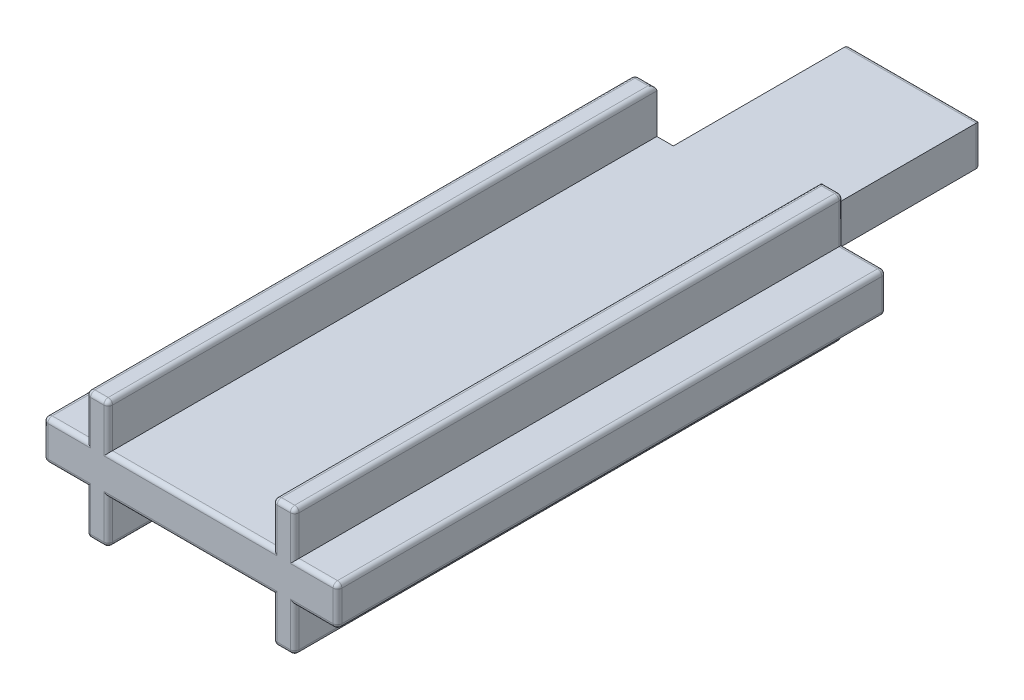
from build123d import *

# Parameters (mm, degrees)
AUFSATZ_LINEAR_AUSTRAGEN1_DEPTH = 25
SKIZZE2_W                       = 6
SKIZZE2_H                       = 1.8
AUFSATZ_LINEAR_AUSTRAGEN2_DEPTH = 8
VERRUNDUNG1_R                   = 0.2


with BuildPart() as part:
    # Skizze1 → Aufsatz-Linear austragen1 (new body)
    with BuildSketch(Plane.XY):
        Polygon((-4.75, 0.9), (-6.7, 0.9), (-6.7, -0.9), (-4.75, -0.9), (-4.75, -2.9), (-3.75, -2.9), (-3.75, -0.9), (3.75, -0.9), (3.75, -2.9), (4.75, -2.9), (4.75, -0.9), (6.7, -0.9), (6.7, 0.9), (4.75, 0.9), (4.75, 2.9), (3.75, 2.9), (3.75, 0.9), (-3.75, 0.9), (-3.75, 2.9), (-4.75, 2.9), align=None)
    extrude(amount=AUFSATZ_LINEAR_AUSTRAGEN1_DEPTH)

    # Skizze2 → Aufsatz-Linear austragen2 (add)
    with BuildSketch(Plane(origin=(0, 0, 0), x_dir=(-1, 0, 0), z_dir=(0, 0, -1))):
        Rectangle(SKIZZE2_W, SKIZZE2_H)
    extrude(amount=AUFSATZ_LINEAR_AUSTRAGEN2_DEPTH)

    # Verrundung1
    verrundung1_edges = [part.edges().sort_by_distance(p)[0] for p in [
        (-4.75, -1.9, 25),
        (-4.25, -2.9, 25),
        (-5.725, 0.9, 0),
        (-4.75, 1.9, 0),
        (-4.25, 2.9, 0),
        (-3.75, -1.9, 25),
        (4.25, 2.9, 0),
        (4.75, 1.9, 0),
        (5.725, 0.9, 0),
        (6.7, 0, 0),
        (5.725, -0.9, 0),
        (4.75, -1.9, 0),
        (4.25, -2.9, 0),
        (0, -0.9, 25),
        (-4.25, -2.9, 0),
        (-4.75, -1.9, 0),
        (-5.725, -0.9, 0),
        (-6.7, 0, 0),
        (3.75, -1.9, 25),
        (4.25, -2.9, 25),
        (-6.7, 0.9, 12.5),
        (-4.75, 2.9, 12.5),
        (-3.75, 2.9, 12.5),
        (3.75, 2.9, 12.5),
        (4.75, 2.9, 12.5),
        (6.7, 0.9, 12.5),
        (6.7, -0.9, 12.5),
        (4.75, -2.9, 12.5),
        (3.75, -2.9, 12.5),
        (-3.75, -2.9, 12.5),
        (-4.75, -2.9, 12.5),
        (-6.7, -0.9, 12.5),
        (4.75, -1.9, 25),
        (5.725, -0.9, 25),
        (6.7, 0, 25),
        (5.725, 0.9, 25),
        (-6.7, 0, 25),
        (4.75, 1.9, 25),
        (4.25, 2.9, 25),
        (3, 0, -8),
        (0, -0.9, -8),
        (-3, 0, -8),
        (0, 0.9, -8),
        (3.75, 1.9, 25),
        (0, 0.9, 25),
        (-3.75, 1.9, 25),
        (-4.25, 2.9, 25),
        (-4.75, 1.9, 25),
        (-5.725, 0.9, 25),
        (-5.725, -0.9, 25),
    ]]
    fillet(verrundung1_edges, radius=VERRUNDUNG1_R)


solid = part.part
